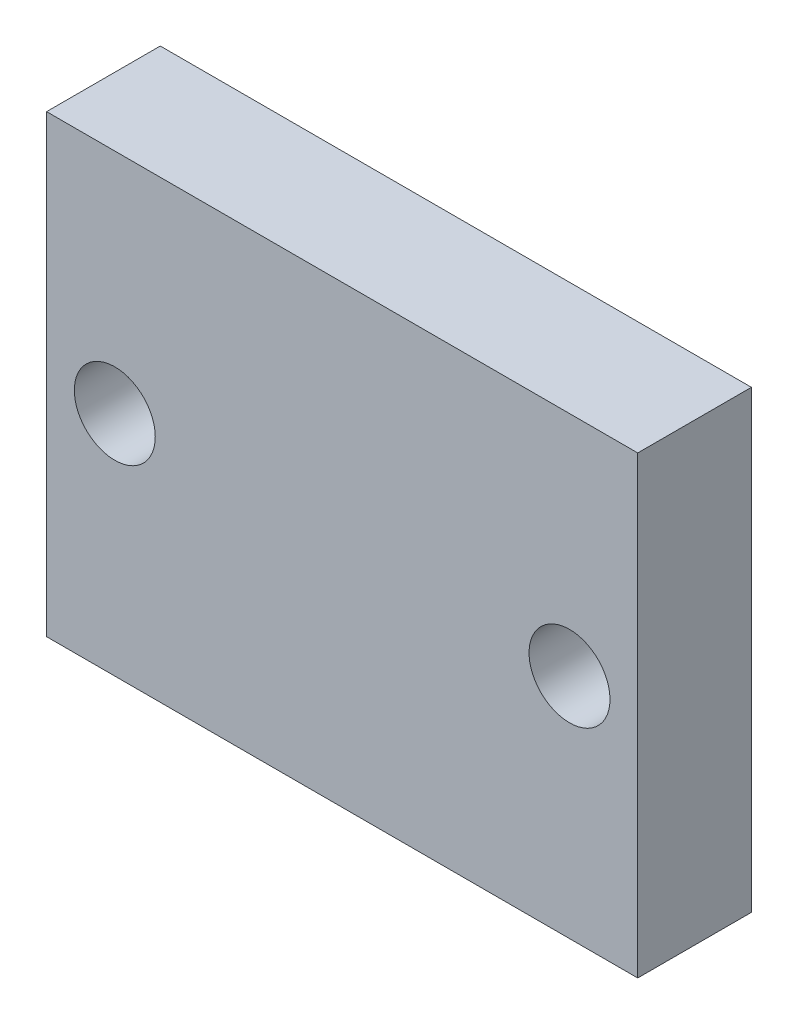
from build123d import *

# Parameters (mm, degrees)
SKETCH2_W           = 16.51
SKETCH2_H           = 12.7
BOSS_EXTRUDE1_DEPTH = 3.175
SKETCH3_R           = 1.1303
CUT_EXTRUDE1_DEPTH  = 4.175


with BuildPart() as part:
    # Sketch2 → Boss-Extrude1 (new body)
    with BuildSketch(Plane.XY):
        with Locations((8.255, 6.35)):
            Rectangle(SKETCH2_W, SKETCH2_H)
    extrude(amount=BOSS_EXTRUDE1_DEPTH)

    # Sketch3 → Cut-Extrude1 (cut, through all)
    with BuildSketch(Plane.XY.offset(3.175)):
        with Locations((1.905, 6.35)):
            Circle(SKETCH3_R)
        with Locations((14.605, 6.35)):
            Circle(SKETCH3_R)
    extrude(amount=-CUT_EXTRUDE1_DEPTH, mode=Mode.SUBTRACT)


solid = part.part
